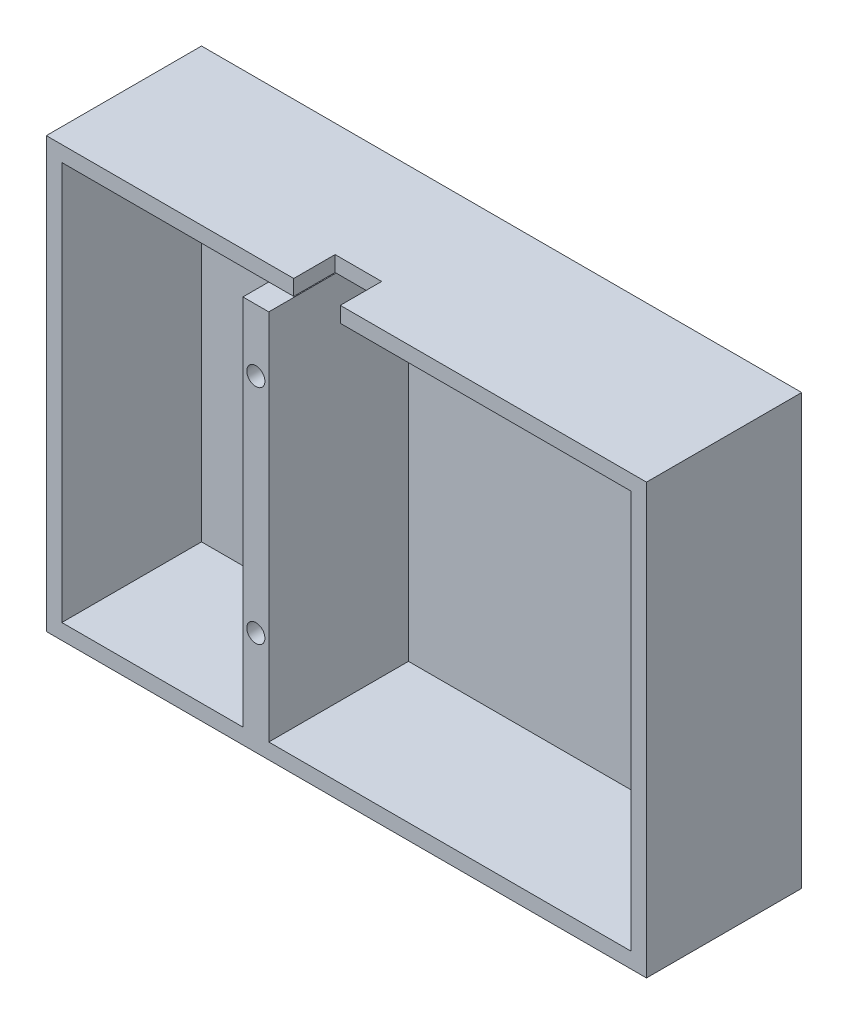
from build123d import *

# Parameters (mm, degrees)
SKETCH1_W           = 116
SKETCH1_H           = 83
SKETCH1_W_2         = 70
SKETCH1_H_2         = 77
SKETCH1_W_3         = 35
BOSS_EXTRUDE1_DEPTH = 30
SKETCH2_W           = 70
SKETCH2_H           = 77
SKETCH2_W_2         = 35
BOSS_EXTRUDE2_DEPTH = 3
SKETCH3_W           = 27
SKETCH3_H           = 5
CUT_EXTRUDE1_DEPTH  = 5
SKETCH5_R           = 5
CUT_EXTRUDE3_DEPTH  = 10
SKETCH6_R           = 1.75
CUT_EXTRUDE4_DEPTH  = 30
SKETCH7_W           = 9
SKETCH7_H           = 8
CUT_EXTRUDE5_DEPTH  = 10


with BuildPart() as part:
    # Sketch1 → Boss-Extrude1 (new body)
    with BuildSketch(Plane.XY):
        with Locations((-58, 41.5)):
            Rectangle(SKETCH1_W, SKETCH1_H)
        with Locations((-38, 41.5)):
            Rectangle(SKETCH1_W_2, SKETCH1_H_2, mode=Mode.SUBTRACT)
        with Locations((-95.5, 41.5)):
            Rectangle(SKETCH1_W_3, SKETCH1_H_2, mode=Mode.SUBTRACT)
    extrude(amount=BOSS_EXTRUDE1_DEPTH)

    # Sketch2 → Boss-Extrude2 (add)
    with BuildSketch(Plane(origin=(0, 0, 0), x_dir=(-1, 0, 0), z_dir=(0, 0, -1))):
        with Locations((38, 41.5)):
            Rectangle(SKETCH2_W, SKETCH2_H)
        with Locations((95.5, 41.5)):
            Rectangle(SKETCH2_W_2, SKETCH2_H)
    extrude(amount=-BOSS_EXTRUDE2_DEPTH)

    # Sketch3 → Cut-Extrude1 (cut)
    with BuildSketch(Plane(origin=(-73, 0, 0), x_dir=(0, 0, -1), z_dir=(1, 0, 0))):
        with Locations((-16.5, 77.5)):
            Rectangle(SKETCH3_W, SKETCH3_H)
    extrude(amount=-CUT_EXTRUDE1_DEPTH, mode=Mode.SUBTRACT)

    # Sketch5 → Cut-Extrude3 (cut)
    with BuildSketch(Plane(origin=(0, 0, 0), x_dir=(-1, 0, 0), z_dir=(0, -1, 0))):
        with Locations((12.5, -8)):
            Circle(SKETCH5_R)
    extrude(amount=-CUT_EXTRUDE3_DEPTH, mode=Mode.SUBTRACT)

    # Sketch6 → Cut-Extrude4 (cut)
    with BuildSketch(Plane.XY.offset(30)):
        with Locations((-75.5, 63)):
            Circle(SKETCH6_R)
        with Locations((-75.5, 20)):
            Circle(SKETCH6_R)
    extrude(amount=-CUT_EXTRUDE4_DEPTH, mode=Mode.SUBTRACT)

    # Sketch7 → Cut-Extrude5 (cut)
    with BuildSketch(Plane(origin=(0, 83, 0), x_dir=(1, 0, 0), z_dir=(0, 1, 0))):
        with Locations((-63.682179336, -26)):
            Rectangle(SKETCH7_W, SKETCH7_H)
    extrude(amount=-CUT_EXTRUDE5_DEPTH, mode=Mode.SUBTRACT)


solid = part.part
